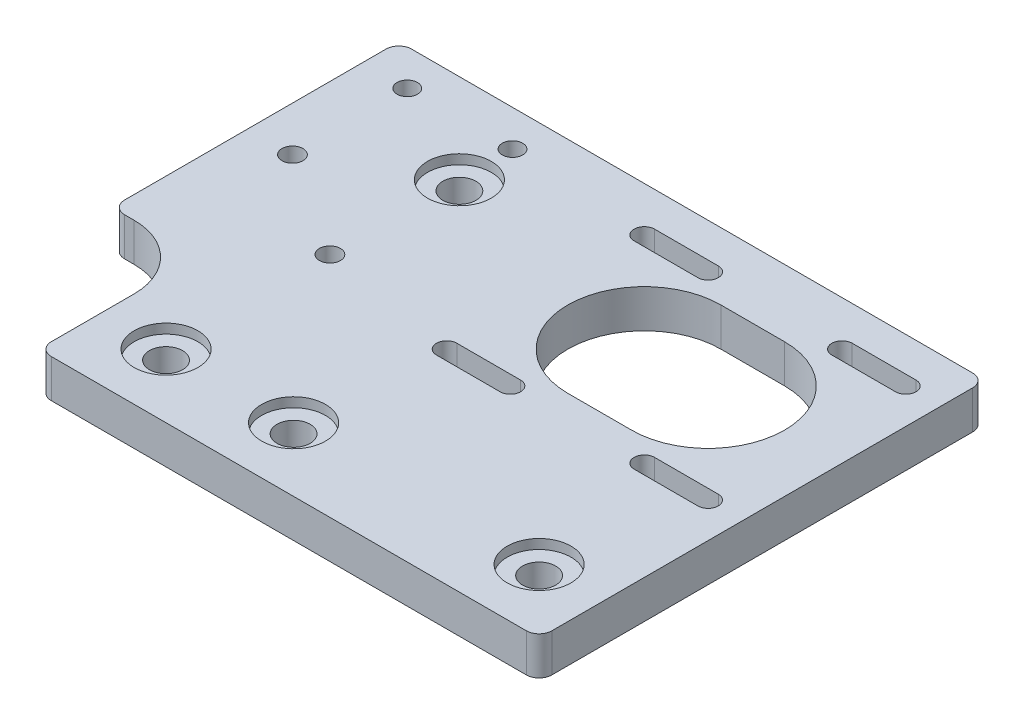
from build123d import *

# Parameters (mm, degrees)
SKETCH3_R             = 2.6
BOSS_EXTRUDE1_DEPTH   = 6
FILLET1_R             = 10
M3_CLEARANCE_HOLE1_D  = 3.2
M4X0_7_TAPPED_HOLE1_D = 3.3
FILLET2_R             = 2
SKETCH5_R             = 5
COUNTERBORE_DEPTH     = 1.5


with BuildPart() as part:
    # Sketch3 → Boss-Extrude1 (new body)
    with BuildSketch(Plane(origin=(0, 0, 0), x_dir=(1, 0, 0), z_dir=(0, 1, 0))):
        Polygon((0, 0), (78.5, 0), (78.5, 70), (0, 70), (-13.5, 70), (-13.5, 25), (0, 25), align=None)
        with Locations((10, 56)):
            Circle(SKETCH3_R, mode=Mode.SUBTRACT)
        with Locations((10, 10)):
            Circle(SKETCH3_R, mode=Mode.SUBTRACT)
        with Locations((68.5, 10)):
            Circle(SKETCH3_R, mode=Mode.SUBTRACT)
        with Locations((30, 10)):
            Circle(SKETCH3_R, mode=Mode.SUBTRACT)
        with BuildLine():
            Line((47.5, 59.5), (57.5, 59.5))
            ThreePointArc((57.5, 59.5), (69.5, 47.5), (57.5, 35.5))
            Line((57.5, 35.5), (47.5, 35.5))
            ThreePointArc((47.5, 35.5), (35.5, 47.5), (47.5, 59.5))
        make_face(mode=Mode.SUBTRACT)
        with BuildLine():
            Line((32, 64.6), (42, 64.6))
            ThreePointArc((42, 64.6), (43.6, 63), (42, 61.4))
            Line((42, 61.4), (32, 61.4))
            ThreePointArc((32, 61.4), (30.4, 63), (32, 64.6))
        make_face(mode=Mode.SUBTRACT)
        with BuildLine():
            Line((63, 64.6), (73, 64.6))
            ThreePointArc((73, 64.6), (74.6, 63), (73, 61.4))
            Line((73, 61.4), (63, 61.4))
            ThreePointArc((63, 61.4), (61.4, 63), (63, 64.6))
        make_face(mode=Mode.SUBTRACT)
        with BuildLine():
            Line((63, 33.6), (73, 33.6))
            ThreePointArc((73, 33.6), (74.6, 32), (73, 30.4))
            Line((73, 30.4), (63, 30.4))
            ThreePointArc((63, 30.4), (61.4, 32), (63, 33.6))
        make_face(mode=Mode.SUBTRACT)
        with BuildLine():
            Line((32, 33.6), (42, 33.6))
            ThreePointArc((42, 33.6), (43.6, 32), (42, 30.4))
            Line((42, 30.4), (32, 30.4))
            ThreePointArc((32, 30.4), (30.4, 32), (32, 33.6))
        make_face(mode=Mode.SUBTRACT)
    extrude(amount=BOSS_EXTRUDE1_DEPTH)

    # Fillet1
    fillet1_edges = [part.edges().sort_by_distance(p)[0] for p in [
        (0, 3, -25),
    ]]
    fillet(fillet1_edges, radius=FILLET1_R)

    # M3 Clearance Hole1 (through all)
    with Locations(Plane(origin=(0, 6, 0), x_dir=(1, 0, 0), z_dir=(0, 1, 0))):
        with Locations((10, 64.325), (-6.5, 64.325)):
            Hole(M3_CLEARANCE_HOLE1_D / 2)

    # M4x0.7 Tapped Hole1 (through all)
    with Locations(Plane(origin=(0, 6, 0), x_dir=(1, 0, 0), z_dir=(0, 1, 0))):
        with Locations((-6.5, 46.325), (10, 35.7)):
            Hole(M4X0_7_TAPPED_HOLE1_D / 2)

    # Fillet2
    fillet2_edges = [part.edges().sort_by_distance(p)[0] for p in [
        (-13.5, 3, -25),
        (-13.5, 3, -70),
        (78.5, 3, -70),
        (78.5, 3, 0),
        (0, 3, 0),
    ]]
    fillet(fillet2_edges, radius=FILLET2_R)

    # Sketch5 → Counterbore (cut)
    with BuildSketch(Plane(origin=(0, 6, 0), x_dir=(1, 0, 0), z_dir=(0, 1, 0))):
        with Locations((10, 56)):
            Circle(SKETCH5_R)
        with Locations((10, 10)):
            Circle(SKETCH5_R)
        with Locations((30, 10)):
            Circle(SKETCH5_R)
        with Locations((68.5, 10)):
            Circle(SKETCH5_R)
    extrude(amount=-COUNTERBORE_DEPTH, mode=Mode.SUBTRACT)


solid = part.part
